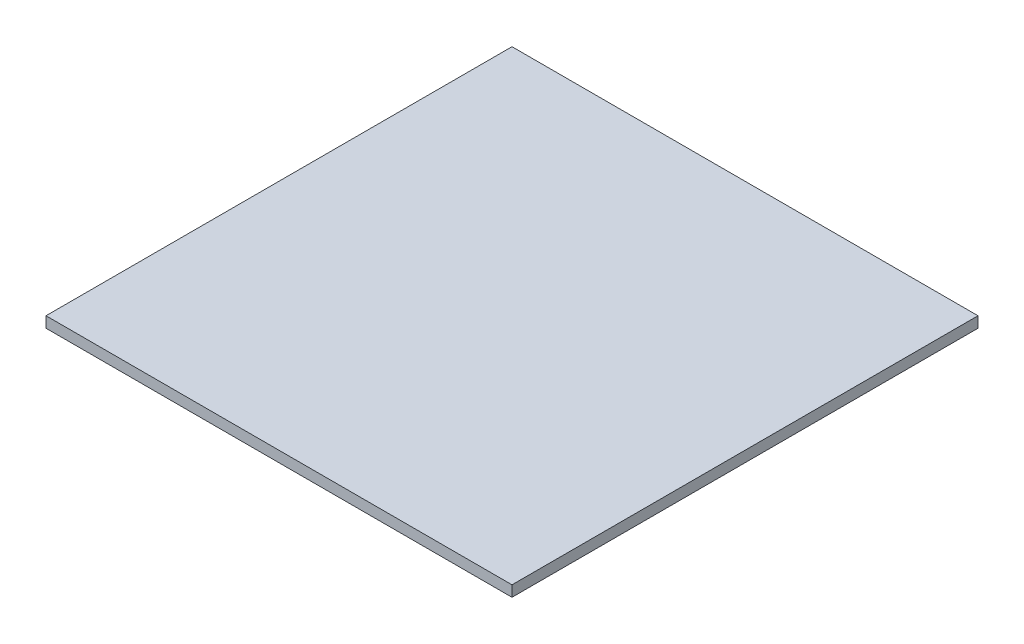
from build123d import *

# Parameters (mm, degrees)
SKETCH1_W           = 430
SKETCH1_H           = 430
BOSS_EXTRUDE1_DEPTH = 10


with BuildPart() as part:
    # Sketch1 → Boss-Extrude1 (new body)
    with BuildSketch(Plane(origin=(0, 0, 0), x_dir=(1, 0, 0), z_dir=(0, 1, 0))):
        Rectangle(SKETCH1_W, SKETCH1_H)
    extrude(amount=BOSS_EXTRUDE1_DEPTH)


solid = part.part
